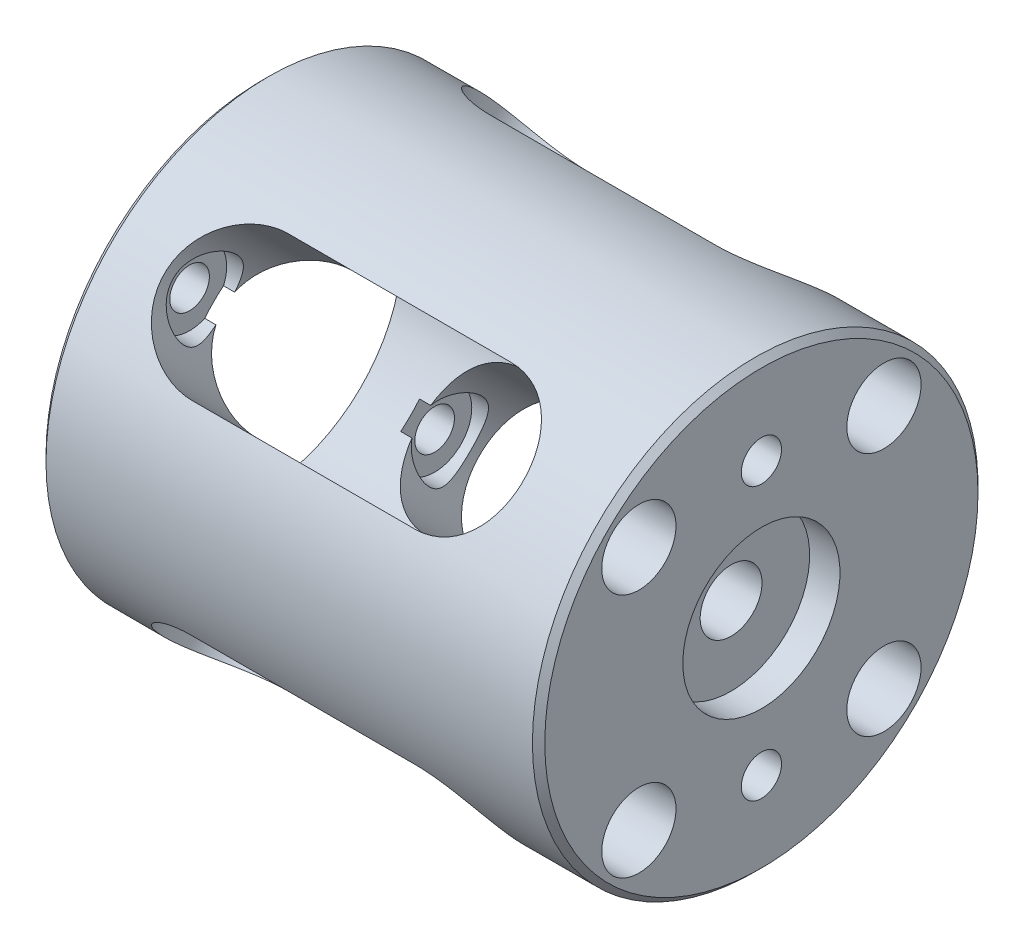
from build123d import *

# Parameters (mm, degrees)
SKETCH7_R               = 1.6
CUT_EXTRUDE1_DEPTH      = 41.3
SKETCH8_R               = 3
CUT_EXTRUDE2_DEPTH      = 36.3
SKETCH9_R               = 1.625
CUT_EXTRUDE3_DEPTH      = 41.3
SKETCH10_R              = 2.425
CUT_EXTRUDE4_DEPTH      = 37
CHAMFER1_SIZE           = 0.5
CUT_EXTRUDE5_DEPTH      = 26.455844123
CUT_EXTRUDE5_DEPTH_BACK = 26.455844123
CUT_EXTRUDE6_DEPTH      = 26.455844264
CUT_EXTRUDE6_DEPTH_BACK = 26.455844264


with BuildPart() as part:
    # Sketch2 → Revolve1 (revolve)
    with BuildSketch(Plane(origin=(0, 0, 0), x_dir=(1, 0, 0), z_dir=(0, 1, 0))):
        Polygon((-40.3, 18), (-40.3, 11.25), (-6.3, 11.25), (-6.3, 2.5), (-2.45, 2.5), (-2.45, 6.35), (0, 6.35), (0, 18), align=None)
    revolve(axis=Axis((-68.587301587, 0, 0), (1, 0, 0)))

    # Sketch7 → Cut-Extrude1 (cut, through all)
    with BuildSketch(Plane(origin=(0, 0, 0), x_dir=(0, 0, -1), z_dir=(1, 0, 0))):
        with Locations((-9.899494937, 9.899494937)):
            Circle(SKETCH7_R)
        with Locations((9.899494937, 9.899494937)):
            Circle(SKETCH7_R)
        with Locations((9.899494937, -9.899494937)):
            Circle(SKETCH7_R)
        with Locations((-9.899494937, -9.899494937)):
            Circle(SKETCH7_R)
    extrude(amount=-CUT_EXTRUDE1_DEPTH, mode=Mode.SUBTRACT)

    # Sketch8 → Cut-Extrude2 (cut)
    with BuildSketch(Plane(origin=(0, 0, 0), x_dir=(0, 0, -1), z_dir=(1, 0, 0))):
        with Locations((-9.899494937, 9.899494937)):
            Circle(SKETCH8_R)
        with Locations((9.899494937, 9.899494937)):
            Circle(SKETCH8_R)
        with Locations((-9.899494937, -9.899494937)):
            Circle(SKETCH8_R)
        with Locations((9.899494937, -9.899494937)):
            Circle(SKETCH8_R)
    extrude(amount=-CUT_EXTRUDE2_DEPTH, mode=Mode.SUBTRACT)

    # Sketch9 → Cut-Extrude3 (cut, through all)
    with BuildSketch(Plane.ZY.offset(40.3)):
        with Locations((0, 11)):
            Circle(SKETCH9_R)
        with Locations((0, -11)):
            Circle(SKETCH9_R)
    extrude(amount=-CUT_EXTRUDE3_DEPTH, mode=Mode.SUBTRACT)

    # Sketch10 → Cut-Extrude4 (cut)
    with BuildSketch(Plane.ZY.offset(40.3)):
        with Locations((0, 11)):
            Circle(SKETCH10_R)
        with Locations((0, -11)):
            Circle(SKETCH10_R)
    extrude(amount=-CUT_EXTRUDE4_DEPTH, mode=Mode.SUBTRACT)

    # Chamfer1
    chamfer1_edges = [part.edges().sort_by_distance(p)[0] for p in [
        (0, 0, 18),
        (-40.3, 0, 18),
    ]]
    chamfer(chamfer1_edges, length=CHAMFER1_SIZE)

    # Sketch13 → Cut-Extrude5 (cut, two sides)
    with BuildSketch(Plane(origin=(0, 0, 0), x_dir=(-1, 0, 0), z_dir=(0, 0.707106781, -0.707106781))) as cut_extrude5_sk:
        with BuildLine():
            Line((12, 5.5), (30, 5.5))
            ThreePointArc((30, 5.5), (35.5, 0), (30, -5.5))
            Line((30, -5.5), (12, -5.5))
            ThreePointArc((12, -5.5), (6.5, 0), (12, 5.5))
        make_face()
    extrude(amount=CUT_EXTRUDE5_DEPTH, mode=Mode.SUBTRACT)
    extrude(cut_extrude5_sk.sketch, amount=-CUT_EXTRUDE5_DEPTH_BACK, mode=Mode.SUBTRACT)

    # Sketch14 → Cut-Extrude6 (cut, two sides)
    with BuildSketch(Plane(origin=(0, 0, 0), x_dir=(-1, 0, 0), z_dir=(0, -0.707106781, -0.707106781))) as cut_extrude6_sk:
        with BuildLine():
            Line((12, 5.5), (30, 5.5))
            ThreePointArc((30, 5.5), (35.5, 0), (30, -5.5))
            Line((30, -5.5), (12, -5.5))
            ThreePointArc((12, -5.5), (6.5, 0), (12, 5.5))
        make_face()
    extrude(amount=CUT_EXTRUDE6_DEPTH, mode=Mode.SUBTRACT)
    extrude(cut_extrude6_sk.sketch, amount=-CUT_EXTRUDE6_DEPTH_BACK, mode=Mode.SUBTRACT)


solid = part.part
